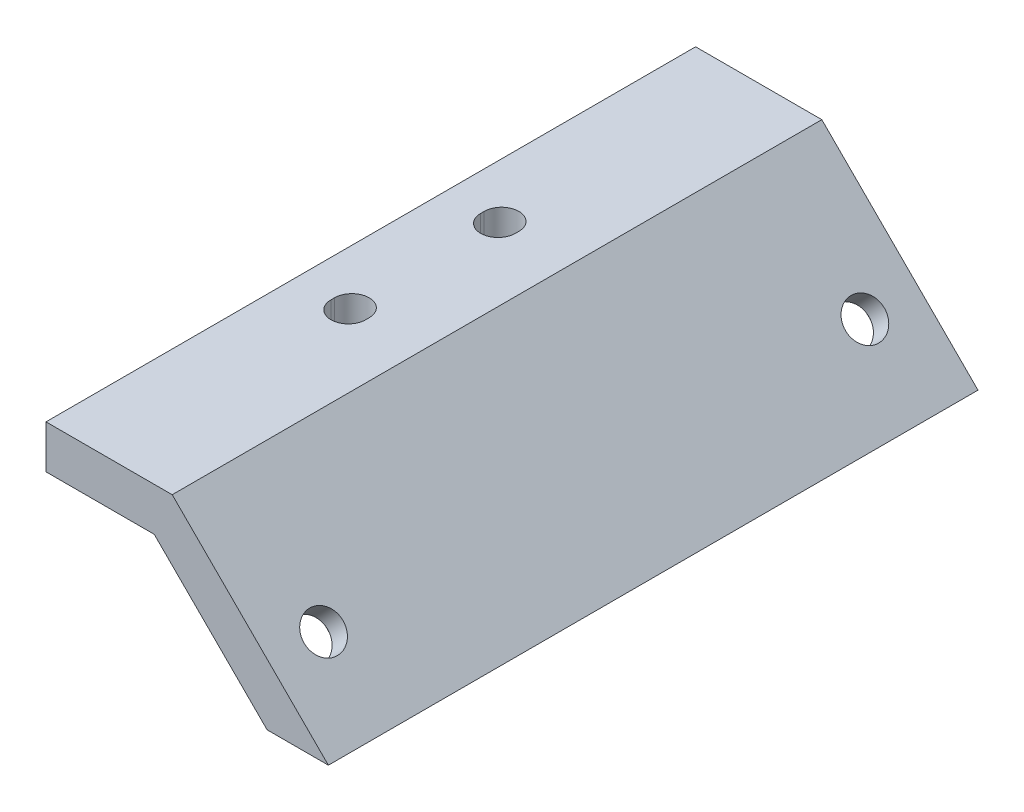
from build123d import *

# Parameters (mm, degrees)
SALIENTE_EXTRUIR1_DEPTH      = 30
SALIENTE_EXTRUIR1_DEPTH_BACK = 30
CROQUIS2_R                   = 1.8
CORTAR_EXTRUIR1_DEPTH        = 4
CROQUIS2_3_R                 = 3.2
CROQUIS2_3_R_2               = 1.8
CORTAR_EXTRUIR2_DEPTH        = 2
CORTAR_EXTRUIR3_DEPTH        = 4


with BuildPart() as part:
    # Croquis1 → Saliente-Extruir1 (new body, two sides)
    with BuildSketch(Plane.XY) as saliente_extruir1_sk:
        Polygon((0, 0), (-14.424978336, 14.424978336), (-26.081832586, 14.424978336), (-26.081832586, 10.424978336), (-16.081832586, 10.424978336), (-5.656854249, 0), align=None)
    extrude(amount=SALIENTE_EXTRUIR1_DEPTH)
    extrude(saliente_extruir1_sk.sketch, amount=-SALIENTE_EXTRUIR1_DEPTH_BACK)

    # Croquis2 → Cortar-Extruir1 (cut)
    with BuildSketch(Plane(origin=(-2.828427125, -2.828427125, 0), x_dir=(-0.707106781, 0.707106781, 0), z_dir=(-0.707106781, -0.707106781, 0))):
        with Locations((7.703145751, -25)):
            Circle(CROQUIS2_R)
        with Locations((7.703145751, 25)):
            Circle(CROQUIS2_R)
    extrude(amount=-CORTAR_EXTRUIR1_DEPTH, mode=Mode.SUBTRACT)

    # Croquis2_3 → Cortar-Extruir2 (cut)
    with BuildSketch(Plane(origin=(-2.828427125, -2.828427125, 0), x_dir=(-0.707106781, 0.707106781, 0), z_dir=(-0.707106781, -0.707106781, 0))):
        with Locations((7.703145751, 25)):
            Circle(CROQUIS2_3_R)
        with Locations((7.703145751, 25)):
            Circle(CROQUIS2_3_R_2, mode=Mode.SUBTRACT)
        with Locations((7.703145751, -25)):
            Circle(CROQUIS2_3_R)
        with Locations((7.703145751, -25)):
            Circle(CROQUIS2_3_R_2, mode=Mode.SUBTRACT)
    extrude(amount=-CORTAR_EXTRUIR2_DEPTH, mode=Mode.SUBTRACT)

    # Croquis3 → Cortar-Extruir3 (cut)
    with BuildSketch(Plane(origin=(0, 14.424978336, 0), x_dir=(1, 0, 0), z_dir=(0, 1, 0))):
        with BuildLine():
            Line((-19.481832586, 7.075), (-19.481832586, 6.75))
            ThreePointArc((-19.481832586, 6.75), (-21.081832586, 5.15), (-22.681832586, 6.75))
            Line((-22.681832586, 6.75), (-22.681832586, 7.075))
            ThreePointArc((-22.681832586, 7.075), (-21.081832586, 8.675), (-19.481832586, 7.075))
        make_face()
        with BuildLine():
            Line((-19.481832586, -7.075), (-19.481832586, -6.75))
            ThreePointArc((-19.481832586, -6.75), (-21.081832586, -5.15), (-22.681832586, -6.75))
            Line((-22.681832586, -6.75), (-22.681832586, -7.075))
            ThreePointArc((-22.681832586, -7.075), (-21.081832586, -8.675), (-19.481832586, -7.075))
        make_face()
    extrude(amount=-CORTAR_EXTRUIR3_DEPTH, mode=Mode.SUBTRACT)


solid = part.part
